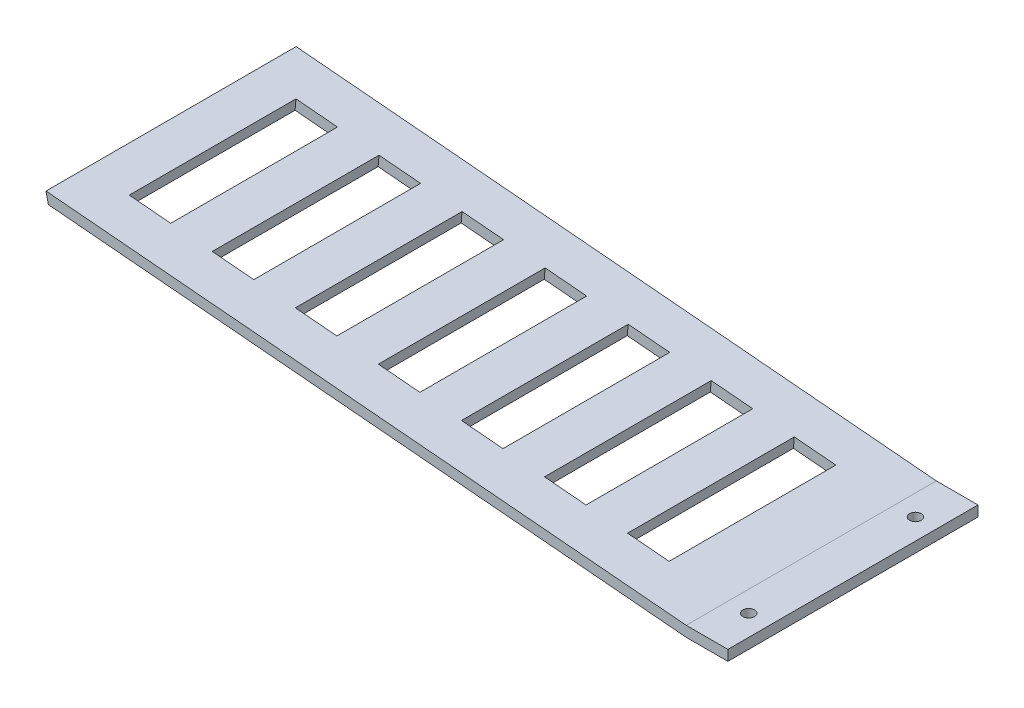
from build123d import *

# Parameters (mm, degrees)
BOSS_EXTRUDE1_DEPTH = 76.2
SKETCH2_R           = 1.778
CUT_EXTRUDE1_DEPTH  = 76.2
SKETCH3_W           = 12.7
SKETCH3_H           = 50.8
CUT_EXTRUDE2_DEPTH  = 76.2
LPATTERN1_COUNT     = 7
LPATTERN1_PITCH     = 25.4


with BuildPart() as part:
    # Sketch1 → Boss-Extrude1 (new body)
    with BuildSketch(Plane.XY):
        Polygon((0, 0), (-12.7, 0), (-207.009499064, 16.999878384), (-207.737954037, 20.238609936), (-12.7, 3.175), (0, 3.175), align=None)
    extrude(amount=BOSS_EXTRUDE1_DEPTH)

    # Sketch2 → Cut-Extrude1 (cut)
    with BuildSketch(Plane(origin=(0, 3.175, 0), x_dir=(1, 0, 0), z_dir=(0, 1, 0))):
        with Locations((-6.35, -12.7)):
            Circle(SKETCH2_R)
        with Locations((-6.35, -63.5)):
            Circle(SKETCH2_R)
    extrude(amount=-CUT_EXTRUDE1_DEPTH, mode=Mode.SUBTRACT)

    # Sketch3 → Cut-Extrude2 (cut)
    with BuildSketch(Plane(origin=(0.179195714, 2.04821638, 0), x_dir=(0.996194698, -0.087155743, 0), z_dir=(0.087155743, 0.996194698, 0))):
        with Locations((-189.661359485, -38.1)):
            Rectangle(SKETCH3_W, SKETCH3_H)
    cut_extrude2 = extrude(amount=-CUT_EXTRUDE2_DEPTH, mode=Mode.SUBTRACT)

    # LPattern1: Cut-Extrude2 ×7
    with Locations(*[Vector(0.996194698, -0.087155743, 0) * (i * LPATTERN1_PITCH) for i in range(1, LPATTERN1_COUNT)]):
        add(cut_extrude2, mode=Mode.SUBTRACT)


solid = part.part
